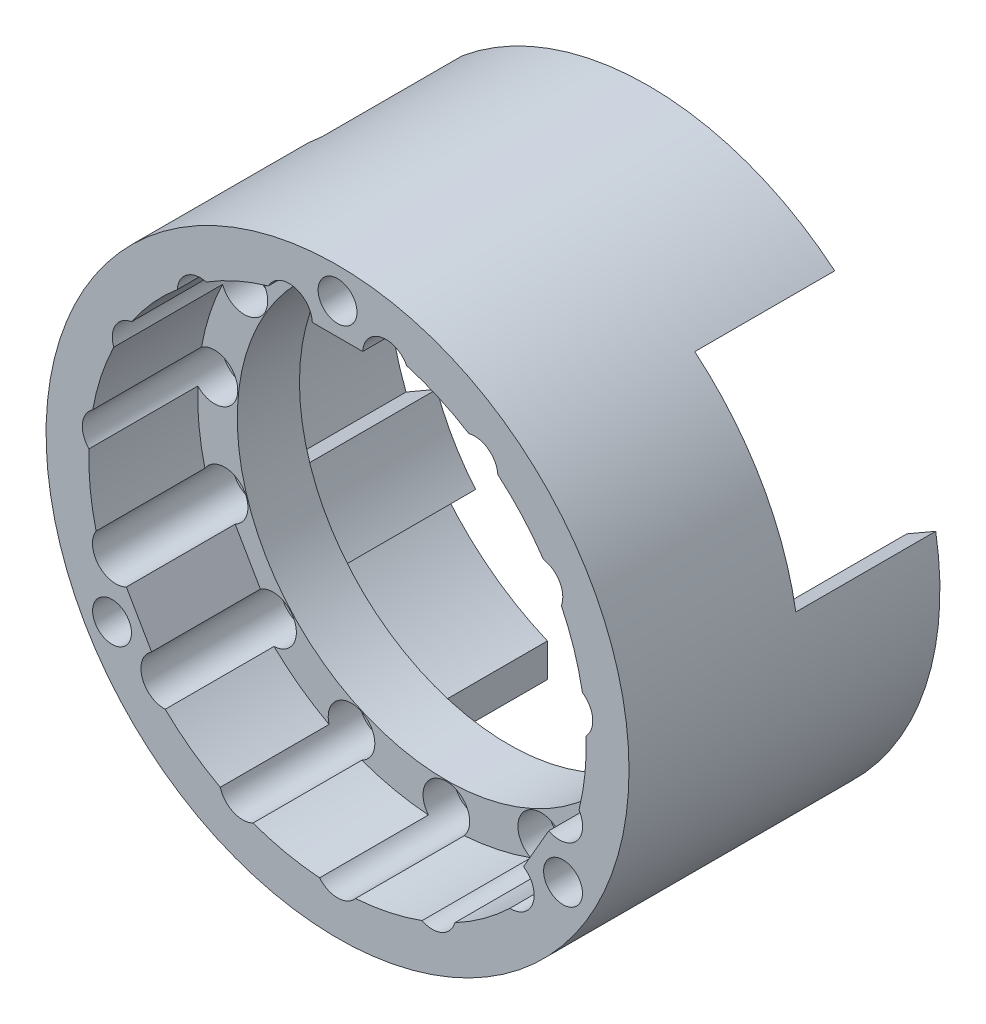
from build123d import *

# Parameters (mm, degrees)
SKETCH_1_R          = 18.75
SKETCH_1_R_2        = 1.25
SKETCH_1_R_3        = 14.75
EXTRUDE_1_DEPTH     = 15
CUT_EXTRUDE_1_DEPTH = 15
SKETCH_3_R          = 18.75
SKETCH_3_R_2        = 1.25
EXTRUDE_4_DEPTH     = 10
SKETCH_5_R          = 18.75
CUT_EXTRUDE_2_DEPTH = 15
SKETCH_6_R          = 1.5
CUT_EXTRUDE_3_DEPTH = 10
SKETCH_7_R          = 18.75
SKETCH_7_R_2        = 12
SKETCH_7_R_3        = 1.5
SKETCH_7_R_4        = 1.25
EXTRUDE_5_DEPTH     = 1
SKETCH_9_R          = 18.75
SKETCH_9_R_2        = 12
SKETCH_9_R_3        = 1.25
EXTRUDE_6_DEPTH     = 1
SKETCH_10_R         = 12
SKETCH_10_R_2       = 11.5
EXTRUDE_7_DEPTH     = 2
SKETCH_13_R         = 18.75
SKETCH_13_R_2       = 11.5
SKETCH_13_R_3       = 1.25
EXTRUDE_9_DEPTH     = 2
SKETCH_14_R         = 18.75
CUT_EXTRUDE_4_DEPTH = 2
SKETCH_15_R         = 18.75
SKETCH_15_R_2       = 1.25
EXTRUDE_10_DEPTH    = 9
CUT_EXTRUDE_6_DEPTH = 9
SKETCH_17_R         = 13.45
CUT_EXTRUDE_8_DEPTH = 10
SKETCH_18_R         = 1.5
CUT_EXTRUDE_9_DEPTH = 1


with BuildPart() as part:
    # 草图1 → 凸台-拉伸1 (new body)
    with BuildSketch(Plane.XY):
        Circle(SKETCH_1_R)
        with Locations((0, 16.75)):
            Circle(SKETCH_1_R_2, mode=Mode.SUBTRACT)
        with Locations((14.505925513, -8.375)):
            Circle(SKETCH_1_R_2, mode=Mode.SUBTRACT)
        with Locations((-14.505925513, -8.375)):
            Circle(SKETCH_1_R_2, mode=Mode.SUBTRACT)
        Circle(SKETCH_1_R_3, mode=Mode.SUBTRACT)
    extrude(amount=EXTRUDE_1_DEPTH)

    # 草图2 → 切除-拉伸1 (cut)
    with BuildSketch(Plane.XY.offset(15)):
        with BuildLine():
            Line((3, 14.75), (1.9e-08, 14.75))
            ThreePointArc((1.9e-08, 14.75), (10.429825029, 10.429825016), (14.75, 0))
            ThreePointArc((14.75, 0), (14.247405929, -3.817580949), (12.773874671, -7.375000061))
            Line((12.773874671, -7.375000061), (14.273874706, -4.776923789))
            Line((14.273874706, -4.776923789), (16.789664748, -2.665925293))
            ThreePointArc((16.789664748, -2.665925293), (14.722431864, 8.5), (6.086073346, 15.873238839))
            Line((6.086073346, 15.873238839), (3, 14.75))
        make_face()
        with BuildLine():
            ThreePointArc((12.773874671, -7.375000061), (-8.5e-08, -14.75), (-12.773874756, -7.374999914))
            Line((-12.773874756, -7.374999914), (-11.273874706, -9.973076211))
            Line((-11.273874706, -9.973076211), (-10.703591402, -13.207313546))
            ThreePointArc((-10.703591402, -13.207313546), (0, -17), (10.703591402, -13.207313546))
            Line((10.703591402, -13.207313546), (11.273874706, -9.973076211))
            Line((11.273874706, -9.973076211), (12.773874671, -7.375000061))
        make_face()
        with BuildLine():
            Line((1.9e-08, 14.75), (-3, 14.75))
            Line((-3, 14.75), (-6.086073346, 15.873238839))
            ThreePointArc((-6.086073346, 15.873238839), (-14.722431864, 8.5), (-16.789664748, -2.665925293))
            Line((-16.789664748, -2.665925293), (-14.273874706, -4.776923789))
            Line((-14.273874706, -4.776923789), (-12.773874756, -7.374999914))
            ThreePointArc((-12.773874756, -7.374999914), (-12.773874676, 7.375000052), (1.9e-08, 14.75))
        make_face()
    extrude(amount=-CUT_EXTRUDE_1_DEPTH, mode=Mode.SUBTRACT)

    # 草图3 → 凸台-拉伸4 (add)
    with BuildSketch(Plane.XY.offset(15)):
        Circle(SKETCH_3_R)
        with Locations((14.505925513, -8.375)):
            Circle(SKETCH_3_R_2, mode=Mode.SUBTRACT)
        with Locations((0, 16.75)):
            Circle(SKETCH_3_R_2, mode=Mode.SUBTRACT)
        with Locations((-14.505925513, -8.375)):
            Circle(SKETCH_3_R_2, mode=Mode.SUBTRACT)
        with BuildLine():
            Line((-11.963527902, -8.778561835), (-13.584221509, -5.971438165))
            ThreePointArc((-13.584221509, -5.971438165), (-13.157604215, -3.624415522), (-15.533866614, -3.833925928))
            ThreePointArc((-15.533866614, -3.833925928), (-15.912350326, -1.672455412), (-15.991532381, 0.520472975))
            ThreePointArc((-15.991532381, 0.520472975), (-13.426045587, 1.411134254), (-15.750291446, 2.815727144))
            ThreePointArc((-15.750291446, 2.815727144), (-15.216904261, 4.94427191), (-14.397296336, 6.97981792))
            ThreePointArc((-14.397296336, 6.97981792), (-11.691342951, 6.75), (-13.243347801, 8.978515413))
            ThreePointArc((-13.243347801, 8.978515413), (-11.890317208, 10.706089702), (-10.31363696, 12.232288938))
            ThreePointArc((-10.31363696, 12.232288938), (-7.935100906, 10.921729424), (-8.446509009, 13.5888368))
            ThreePointArc((-8.446509009, 13.5888368), (-6.507786289, 14.616727322), (-4.446656057, 15.369686071))
            ThreePointArc((-4.446656057, 15.369686071), (-3.439966191, 13.207027264), (-1.620693607, 14.75))
            Line((-1.620693607, 14.75), (1.620693607, 14.75))
            ThreePointArc((1.620693607, 14.75), (3.439966191, 13.207027264), (4.446656057, 15.369686071))
            ThreePointArc((4.446656057, 15.369686071), (6.507786289, 14.616727322), (8.446509009, 13.5888368))
            ThreePointArc((8.446509009, 13.5888368), (7.935100906, 10.921729424), (10.31363696, 12.232288938))
            ThreePointArc((10.31363696, 12.232288938), (11.890317208, 10.706089702), (13.243347801, 8.978515413))
            ThreePointArc((13.243347801, 8.978515413), (11.691342951, 6.75), (14.397296336, 6.97981792))
            ThreePointArc((14.397296336, 6.97981792), (15.216904261, 4.94427191), (15.750291446, 2.815727144))
            ThreePointArc((15.750291446, 2.815727144), (13.426045587, 1.411134254), (15.991532381, 0.520472975))
            ThreePointArc((15.991532381, 0.520472975), (15.912350326, -1.672455412), (15.533866614, -3.833925928))
            ThreePointArc((15.533866614, -3.833925928), (13.157604215, -3.624415522), (13.584221509, -5.971438165))
            Line((13.584221509, -5.971438165), (11.963527902, -8.778561835))
            ThreePointArc((11.963527902, -8.778561835), (9.717638024, -9.582611742), (11.087210557, -11.535760143))
            ThreePointArc((11.087210557, -11.535760143), (9.404564037, -12.94427191), (7.545023372, -14.109309775))
            ThreePointArc((7.545023372, -14.109309775), (5.490944682, -12.332863678), (5.436654486, -15.048016082))
            ThreePointArc((5.436654486, -15.048016082), (3.326587053, -15.650361612), (1.153948535, -15.958333333))
            ThreePointArc((1.153948535, -15.958333333), (0, -13.5), (-1.153948535, -15.958333333))
            ThreePointArc((-1.153948535, -15.958333333), (-3.326587053, -15.650361612), (-5.436654486, -15.048016082))
            ThreePointArc((-5.436654486, -15.048016082), (-5.490944682, -12.332863678), (-7.545023372, -14.109309775))
            ThreePointArc((-7.545023372, -14.109309775), (-9.404564037, -12.94427191), (-11.087210557, -11.535760143))
            ThreePointArc((-11.087210557, -11.535760143), (-9.717638024, -9.582611742), (-11.963527902, -8.778561835))
        make_face(mode=Mode.SUBTRACT)
    extrude(amount=EXTRUDE_4_DEPTH)

    # 草图5 → 切除-拉伸2 (cut)
    with BuildSketch(Plane.XY):
        Circle(SKETCH_5_R)
    extrude(amount=CUT_EXTRUDE_2_DEPTH, mode=Mode.SUBTRACT)

    # 草图6 → 切除-拉伸3 (cut)
    with BuildSketch(Plane(origin=(0, 0, 15), x_dir=(-1, 0, 0), z_dir=(0, 0, -1))):
        with Locations((3.118675362, 14.672214011)):
            Circle(SKETCH_6_R)
        with Locations((8.816778784, 12.135254916)):
            Circle(SKETCH_6_R)
        with Locations((12.990381057, 7.5)):
            Circle(SKETCH_6_R)
        with Locations((14.917828431, 1.567926949)):
            Circle(SKETCH_6_R)
        with Locations((14.265847744, -4.635254916)):
            Circle(SKETCH_6_R)
        with Locations((11.147172382, -10.036959095)):
            Circle(SKETCH_6_R)
        with Locations((6.101049646, -13.703181865)):
            Circle(SKETCH_6_R)
        with Locations((0, -15)):
            Circle(SKETCH_6_R)
        with Locations((-6.101049646, -13.703181865)):
            Circle(SKETCH_6_R)
        with Locations((-11.147172382, -10.036959095)):
            Circle(SKETCH_6_R)
        with Locations((-14.265847744, -4.635254916)):
            Circle(SKETCH_6_R)
        with Locations((-14.917828431, 1.567926949)):
            Circle(SKETCH_6_R)
        with Locations((-12.990381057, 7.5)):
            Circle(SKETCH_6_R)
        with Locations((-8.816778784, 12.135254916)):
            Circle(SKETCH_6_R)
        with Locations((-3.118675362, 14.672214011)):
            Circle(SKETCH_6_R)
    extrude(amount=-CUT_EXTRUDE_3_DEPTH, mode=Mode.SUBTRACT)

    # 草图7 → 凸台-拉伸5 (add)
    with BuildSketch(Plane(origin=(0, 0, 15), x_dir=(-1, 0, 0), z_dir=(0, 0, -1))):
        Circle(SKETCH_7_R)
        Circle(SKETCH_7_R_2, mode=Mode.SUBTRACT)
        with Locations((3.118675362, 14.672214011)):
            Circle(SKETCH_7_R_3, mode=Mode.SUBTRACT)
        with Locations((8.816778784, 12.135254916)):
            Circle(SKETCH_7_R_3, mode=Mode.SUBTRACT)
        with Locations((12.990381057, 7.5)):
            Circle(SKETCH_7_R_3, mode=Mode.SUBTRACT)
        with Locations((14.917828431, 1.567926949)):
            Circle(SKETCH_7_R_3, mode=Mode.SUBTRACT)
        with Locations((14.265847744, -4.635254916)):
            Circle(SKETCH_7_R_3, mode=Mode.SUBTRACT)
        with Locations((11.147172382, -10.036959095)):
            Circle(SKETCH_7_R_3, mode=Mode.SUBTRACT)
        with Locations((6.101049646, -13.703181865)):
            Circle(SKETCH_7_R_3, mode=Mode.SUBTRACT)
        with Locations((0, -15)):
            Circle(SKETCH_7_R_3, mode=Mode.SUBTRACT)
        with Locations((-6.101049646, -13.703181865)):
            Circle(SKETCH_7_R_3, mode=Mode.SUBTRACT)
        with Locations((-11.147172382, -10.036959095)):
            Circle(SKETCH_7_R_3, mode=Mode.SUBTRACT)
        with Locations((-14.265847744, -4.635254916)):
            Circle(SKETCH_7_R_3, mode=Mode.SUBTRACT)
        with Locations((-14.917828431, 1.567926949)):
            Circle(SKETCH_7_R_3, mode=Mode.SUBTRACT)
        with Locations((-12.990381057, 7.5)):
            Circle(SKETCH_7_R_3, mode=Mode.SUBTRACT)
        with Locations((-8.816778784, 12.135254916)):
            Circle(SKETCH_7_R_3, mode=Mode.SUBTRACT)
        with Locations((-3.118675362, 14.672214011)):
            Circle(SKETCH_7_R_3, mode=Mode.SUBTRACT)
        with Locations((14.505925513, -8.375)):
            Circle(SKETCH_7_R_4, mode=Mode.SUBTRACT)
        with Locations((-14.505925513, -8.375)):
            Circle(SKETCH_7_R_4, mode=Mode.SUBTRACT)
        with Locations((0, 16.75)):
            Circle(SKETCH_7_R_4, mode=Mode.SUBTRACT)
    extrude(amount=-EXTRUDE_5_DEPTH)

    # 草图9 → 凸台-拉伸6 (add)
    with BuildSketch(Plane(origin=(0, 0, 15), x_dir=(-1, 0, 0), z_dir=(0, 0, -1))):
        Circle(SKETCH_9_R)
        Circle(SKETCH_9_R_2, mode=Mode.SUBTRACT)
        with Locations((0, 16.75)):
            Circle(SKETCH_9_R_3, mode=Mode.SUBTRACT)
        with Locations((-14.505925513, -8.375)):
            Circle(SKETCH_9_R_3, mode=Mode.SUBTRACT)
        with Locations((14.505925513, -8.375)):
            Circle(SKETCH_9_R_3, mode=Mode.SUBTRACT)
    extrude(amount=EXTRUDE_6_DEPTH)

    # 草图10 → 凸台-拉伸7 (add)
    with BuildSketch(Plane.XY.offset(16)):
        Circle(SKETCH_10_R)
        Circle(SKETCH_10_R_2, mode=Mode.SUBTRACT)
    extrude(amount=-EXTRUDE_7_DEPTH)

    # 草图13 → 凸台-拉伸9 (add)
    with BuildSketch(Plane(origin=(0, 0, 14), x_dir=(-1, 0, 0), z_dir=(0, 0, -1))):
        Circle(SKETCH_13_R)
        Circle(SKETCH_13_R_2, mode=Mode.SUBTRACT)
        with Locations((0, 16.75)):
            Circle(SKETCH_13_R_3, mode=Mode.SUBTRACT)
        with Locations((-14.505925513, -8.375)):
            Circle(SKETCH_13_R_3, mode=Mode.SUBTRACT)
        with Locations((14.505925513, -8.375)):
            Circle(SKETCH_13_R_3, mode=Mode.SUBTRACT)
    extrude(amount=EXTRUDE_9_DEPTH)

    # 草图14 → 切除-拉伸4 (cut)
    with BuildSketch(Plane.XY.offset(25)):
        Circle(SKETCH_14_R)
    extrude(amount=-CUT_EXTRUDE_4_DEPTH, mode=Mode.SUBTRACT)

    # 草图15 → 凸台-拉伸10 (add)
    with BuildSketch(Plane(origin=(0, 0, 12), x_dir=(-1, 0, 0), z_dir=(0, 0, -1))):
        Circle(SKETCH_15_R)
        with Locations((14.505925513, -8.375)):
            Circle(SKETCH_15_R_2, mode=Mode.SUBTRACT)
        with Locations((0, 16.75)):
            Circle(SKETCH_15_R_2, mode=Mode.SUBTRACT)
        with Locations((-14.505925513, -8.375)):
            Circle(SKETCH_15_R_2, mode=Mode.SUBTRACT)
        with BuildLine():
            Line((11.119316877, -9.306491938), (13.093443624, -10.446254547))
            ThreePointArc((13.093443624, -10.446254547), (0, -16.75), (-13.093443624, -10.446254547))
            Line((-13.093443624, -10.446254547), (-11.119316877, -9.306491938))
            ThreePointArc((-11.119316877, -9.306491938), (-12.557368355, -7.25), (-13.619316877, -4.976364919))
            Line((-13.619316877, -4.976364919), (-15.593443624, -6.116127528))
            ThreePointArc((-15.593443624, -6.116127528), (-14.505925513, 8.375), (-2.5, 16.562382075))
            Line((-2.5, 16.562382075), (-2.5, 14.282856857))
            ThreePointArc((-2.5, 14.282856857), (0, 14.5), (2.5, 14.282856857))
            Line((2.5, 14.282856857), (2.5, 16.562382075))
            ThreePointArc((2.5, 16.562382075), (14.505925513, 8.375), (15.593443624, -6.116127528))
            Line((15.593443624, -6.116127528), (13.619316877, -4.976364919))
            ThreePointArc((13.619316877, -4.976364919), (12.557368355, -7.25), (11.119316877, -9.306491938))
        make_face(mode=Mode.SUBTRACT)
    extrude(amount=EXTRUDE_10_DEPTH)

    # 草图16 → 切除-拉伸6 (cut)
    with BuildSketch(Plane(origin=(0, 0, 3), x_dir=(-1, 0, 0), z_dir=(0, 0, -1))):
        with BuildLine():
            Line((-16.619157602, 2.089521616), (-18.481033287, 3.164476044))
            ThreePointArc((-18.481033287, 3.164476044), (-16.237976321, 9.375), (-11.981033287, 14.422806293))
            Line((-11.981033287, 14.422806293), (-10.119157602, 13.347851865))
            ThreePointArc((-10.119157602, 13.347851865), (-14.505925513, 8.375), (-16.619157602, 2.089521616))
        make_face()
        with BuildLine():
            Line((6.5, -15.437373481), (6.5, -17.587282337))
            ThreePointArc((6.5, -17.587282337), (0, -18.75), (-6.5, -17.587282337))
            Line((-6.5, -17.587282337), (-6.5, -15.437373481))
            ThreePointArc((-6.5, -15.437373481), (0, -16.75), (6.5, -15.437373481))
        make_face()
        with BuildLine():
            Line((10.119157602, 13.347851865), (11.981033287, 14.422806293))
            ThreePointArc((11.981033287, 14.422806293), (16.237976321, 9.375), (18.481033287, 3.164476044))
            Line((18.481033287, 3.164476044), (16.619157602, 2.089521616))
            ThreePointArc((16.619157602, 2.089521616), (14.505925513, 8.375), (10.119157602, 13.347851865))
        make_face()
    extrude(amount=-CUT_EXTRUDE_6_DEPTH, mode=Mode.SUBTRACT)

    # 草图17 → 切除-拉伸8 (cut)
    with BuildSketch(Plane.XY.offset(16)):
        Circle(SKETCH_17_R)
    extrude(amount=-CUT_EXTRUDE_8_DEPTH, mode=Mode.SUBTRACT)

    # 草图18 → 切除-拉伸9 (cut)
    with BuildSketch(Plane.XY.offset(15)):
        with Locations((14.265847744, -4.635254916)):
            Circle(SKETCH_18_R)
        with Locations((11.147172382, -10.036959095)):
            Circle(SKETCH_18_R)
        with Locations((6.101049646, -13.703181865)):
            Circle(SKETCH_18_R)
        with Locations((0, -15)):
            Circle(SKETCH_18_R)
        with Locations((-6.101049646, -13.703181865)):
            Circle(SKETCH_18_R)
        with Locations((-11.147172382, -10.036959095)):
            Circle(SKETCH_18_R)
        with Locations((-14.265847744, -4.635254916)):
            Circle(SKETCH_18_R)
        with Locations((-14.917828431, 1.567926949)):
            Circle(SKETCH_18_R)
        with Locations((-12.990381057, 7.5)):
            Circle(SKETCH_18_R)
        with Locations((-8.816778784, 12.135254916)):
            Circle(SKETCH_18_R)
        with Locations((-3.118675362, 14.672214011)):
            Circle(SKETCH_18_R)
        with Locations((3.118675362, 14.672214011)):
            Circle(SKETCH_18_R)
        with Locations((8.816778784, 12.135254916)):
            Circle(SKETCH_18_R)
        with Locations((12.990381057, 7.5)):
            Circle(SKETCH_18_R)
        with Locations((14.917828431, 1.567926949)):
            Circle(SKETCH_18_R)
    extrude(amount=-CUT_EXTRUDE_9_DEPTH, mode=Mode.SUBTRACT)


solid = part.part
